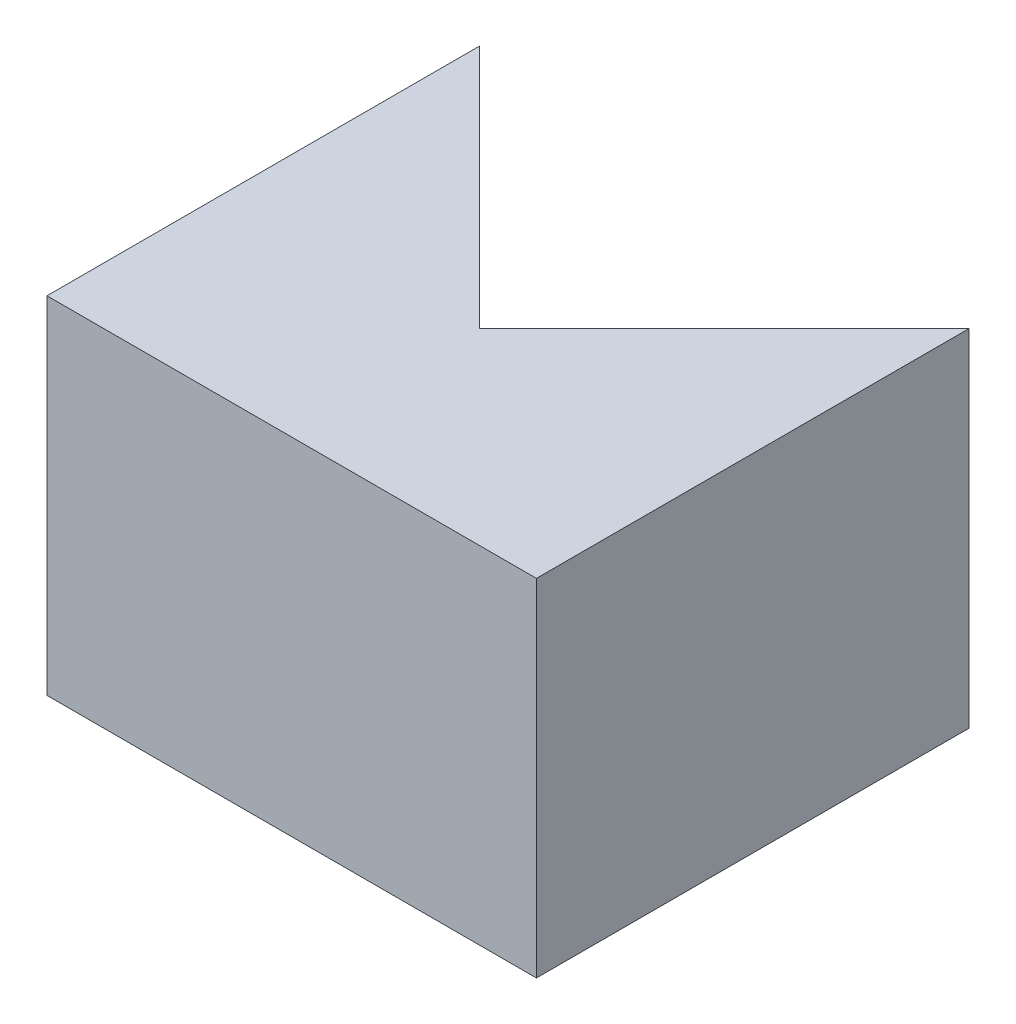
from build123d import *

# Parameters (mm, degrees)
BOSS_EXTRUDE1_DEPTH = 50.8


with BuildPart() as part:
    # Sketch3 → Boss-Extrude1 (new body)
    with BuildSketch(Plane(origin=(0, 0, 0), x_dir=(1, 0, 0), z_dir=(0, 1, 0))):
        Polygon((17.960512242, -17.960512242), (-17.960512242, 17.960512242), (-17.960512242, -45.539487758), (53.881536726, -45.539487758), (53.881536726, 17.960512242), align=None)
    extrude(amount=BOSS_EXTRUDE1_DEPTH)


solid = part.part
